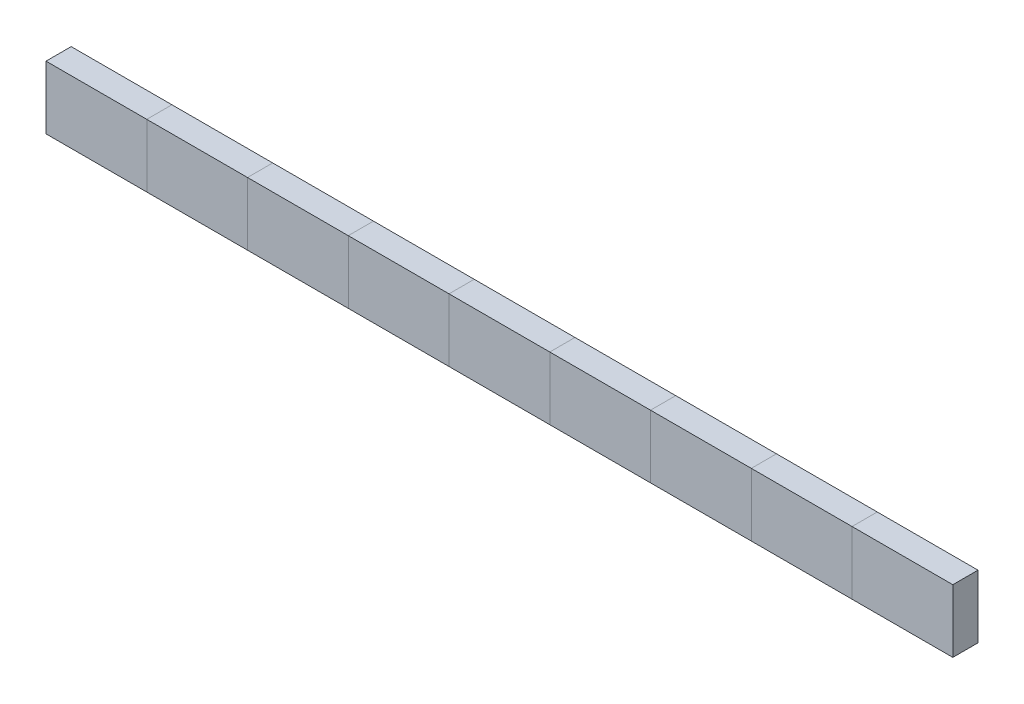
from build123d import *

# Parameters (mm, degrees)
SKETCH1_W            = 2.032
SKETCH1_H            = 1.27
BOSS_EXTRUDE1_DEPTH  = 0.508
SKETCH3_W            = 0.508
SKETCH3_H            = 1.27
BOSS_EXTRUDE3_DEPTH  = 2.032
SKETCH4_W            = 0.508
SKETCH4_H            = 1.27
BOSS_EXTRUDE4_DEPTH  = 2.032
SKETCH5_W            = 0.508
SKETCH5_H            = 1.27
BOSS_EXTRUDE5_DEPTH  = 2.032
SKETCH6_W            = 0.508
SKETCH6_H            = 1.27
BOSS_EXTRUDE6_DEPTH  = 2.032
SKETCH7_W            = 0.508
SKETCH7_H            = 1.27
BOSS_EXTRUDE7_DEPTH  = 2.032
SKETCH8_W            = 0.508
SKETCH8_H            = 1.27
BOSS_EXTRUDE8_DEPTH  = 2.032
SKETCH9_W            = 0.508
SKETCH9_H            = 1.27
BOSS_EXTRUDE9_DEPTH  = 2.032
SKETCH10_W           = 0.508
SKETCH10_H           = 1.27
BOSS_EXTRUDE10_DEPTH = 2.032


with BuildPart() as part:
    # Sketch1 → Boss-Extrude1 (new body)
    with BuildSketch(Plane.XY):
        with Locations((1.016, 0.635)):
            Rectangle(SKETCH1_W, SKETCH1_H)
    extrude(amount=BOSS_EXTRUDE1_DEPTH)


with BuildPart() as body_2:
    # Sketch3 → Boss-Extrude3 (new body)
    with BuildSketch(Plane(origin=(2.032, 0, 0), x_dir=(0, 0, -1), z_dir=(1, 0, 0))):
        with Locations((-0.254, 0.635)):
            Rectangle(SKETCH3_W, SKETCH3_H)
    extrude(amount=BOSS_EXTRUDE3_DEPTH)


with BuildPart() as body_3:
    # Sketch4 → Boss-Extrude4 (new body)
    with BuildSketch(Plane(origin=(4.064, 0, 0), x_dir=(0, 0, -1), z_dir=(1, 0, 0))):
        with Locations((-0.254, 0.635)):
            Rectangle(SKETCH4_W, SKETCH4_H)
    extrude(amount=BOSS_EXTRUDE4_DEPTH)


with BuildPart() as body_4:
    # Sketch5 → Boss-Extrude5 (new body)
    with BuildSketch(Plane(origin=(6.096, 0, 0), x_dir=(0, 0, -1), z_dir=(1, 0, 0))):
        with Locations((-0.254, 0.635)):
            Rectangle(SKETCH5_W, SKETCH5_H)
    extrude(amount=BOSS_EXTRUDE5_DEPTH)


with BuildPart() as body_5:
    # Sketch6 → Boss-Extrude6 (new body)
    with BuildSketch(Plane(origin=(8.128, 0, 0), x_dir=(0, 0, -1), z_dir=(1, 0, 0))):
        with Locations((-0.254, 0.635)):
            Rectangle(SKETCH6_W, SKETCH6_H)
    extrude(amount=BOSS_EXTRUDE6_DEPTH)


with BuildPart() as body_6:
    # Sketch7 → Boss-Extrude7 (new body)
    with BuildSketch(Plane(origin=(10.16, 0, 0), x_dir=(0, 0, -1), z_dir=(1, 0, 0))):
        with Locations((-0.254, 0.635)):
            Rectangle(SKETCH7_W, SKETCH7_H)
    extrude(amount=BOSS_EXTRUDE7_DEPTH)


with BuildPart() as body_7:
    # Sketch8 → Boss-Extrude8 (new body)
    with BuildSketch(Plane(origin=(12.192, 0, 0), x_dir=(0, 0, -1), z_dir=(1, 0, 0))):
        with Locations((-0.254, 0.635)):
            Rectangle(SKETCH8_W, SKETCH8_H)
    extrude(amount=BOSS_EXTRUDE8_DEPTH)


with BuildPart() as body_8:
    # Sketch9 → Boss-Extrude9 (new body)
    with BuildSketch(Plane(origin=(14.224, 0, 0), x_dir=(0, 0, -1), z_dir=(1, 0, 0))):
        with Locations((-0.254, 0.635)):
            Rectangle(SKETCH9_W, SKETCH9_H)
    extrude(amount=BOSS_EXTRUDE9_DEPTH)


with BuildPart() as body_9:
    # Sketch10 → Boss-Extrude10 (new body)
    with BuildSketch(Plane(origin=(16.256, 0, 0), x_dir=(0, 0, -1), z_dir=(1, 0, 0))):
        with Locations((-0.254, 0.635)):
            Rectangle(SKETCH10_W, SKETCH10_H)
    extrude(amount=BOSS_EXTRUDE10_DEPTH)


solid = Compound([part.part, body_2.part, body_3.part, body_4.part, body_5.part, body_6.part, body_7.part, body_8.part, body_9.part])
